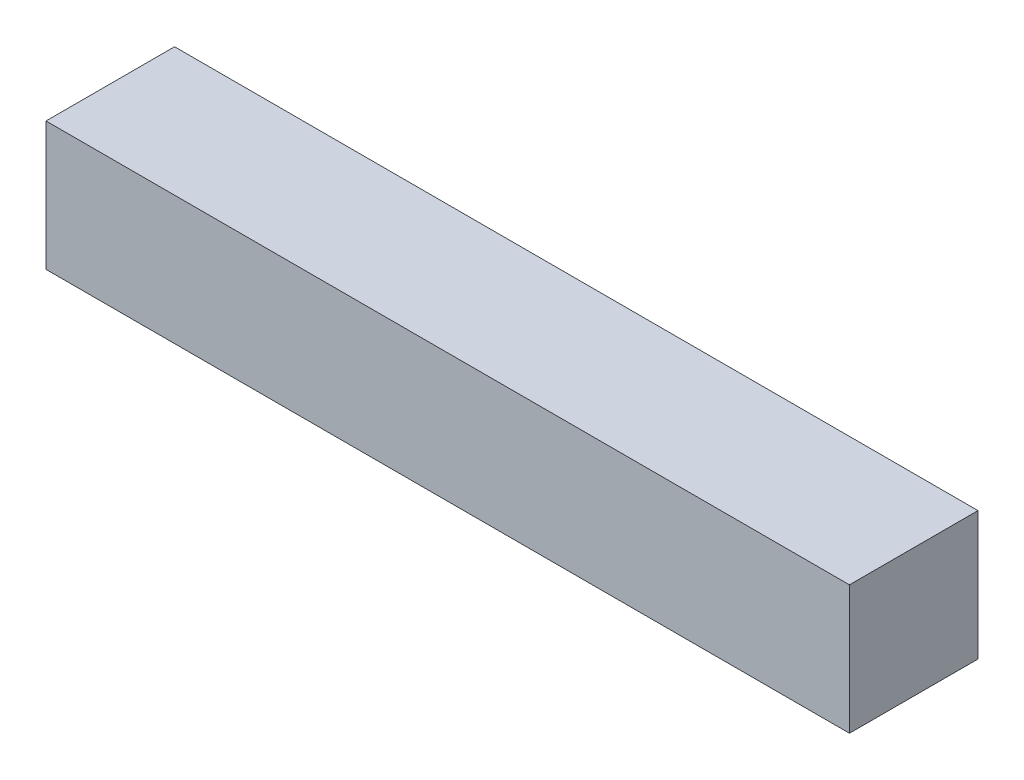
from build123d import *

# Parameters (mm, degrees)
SKETCH1_W           = 25
SKETCH1_H           = 4
BOSS_EXTRUDE1_DEPTH = 4


with BuildPart() as part:
    # Sketch1 → Boss-Extrude1 (new body)
    with BuildSketch(Plane(origin=(0, 0, 0), x_dir=(1, 0, 0), z_dir=(0, 1, 0))):
        with Locations((12.5, -2)):
            Rectangle(SKETCH1_W, SKETCH1_H)
    extrude(amount=BOSS_EXTRUDE1_DEPTH)


solid = part.part
